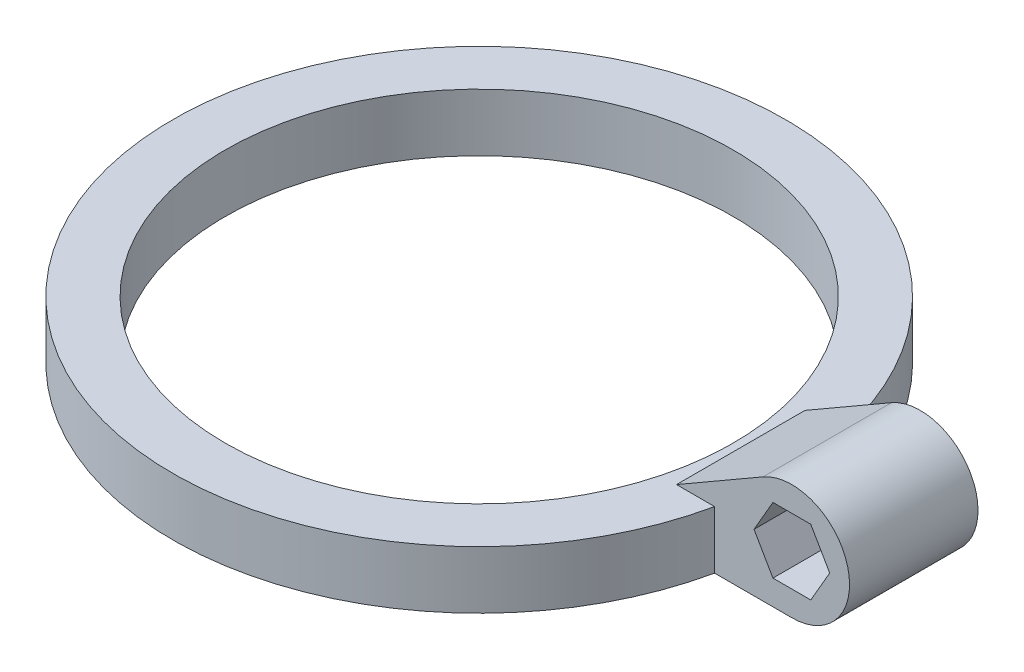
from build123d import *

# Parameters (mm, degrees)
SKETCH2_R                      = 38.75
BOSS_EXTRUDE1_DEPTH            = 8.8
BOSS_EXTRUDE2_DEPTH            = 9.8
BOSS_EXTRUDE2_DEPTH_BACK       = 9.8
CUT_EXTRUDE1_REACH             = 116.591
CUT_EXTRUDE1_DIRECTION_2_REACH = 116.591
CUT_EXTRUDE2_REACH             = 116.591
SKETCH5_W                      = 2
SKETCH5_H                      = 1


with BuildPart() as part:
    # Sketch2 → Boss-Extrude1 (new body)
    with BuildSketch(Plane(origin=(0, 0, 0), x_dir=(1, 0, 0), z_dir=(0, 1, 0))):
        with BuildLine():
            Line((-11.788704897, -9.8), (0, -9.8))
            Line((0, -9.8), (0, 9.8))
            Line((0, 9.8), (-11.788704897, 9.8))
            ThreePointArc((-11.788704897, 9.8), (-104.25, 0), (-11.788704897, -9.8))
        make_face()
        with Locations((-57.5, 0)):
            Circle(SKETCH2_R, mode=Mode.SUBTRACT)
    extrude(amount=-BOSS_EXTRUDE1_DEPTH)

    # Sketch3 → Boss-Extrude2 (add, two sides: drawn at the far end of the back side and taken through both)
    with BuildSketch(Plane.XY.offset(-BOSS_EXTRUDE2_DEPTH_BACK)):
        with BuildLine():
            Line((0, -8.8), (0, 0))
            Line((0, 0), (-17.6, 0))
            Line((-17.6, 0), (-4.4, 7.621023553))
            ThreePointArc((-4.4, 7.621023553), (8.500147271, 2.277607597), (0, -8.8))
        make_face()
    extrude(amount=BOSS_EXTRUDE2_DEPTH + BOSS_EXTRUDE2_DEPTH_BACK)

    # Sketch4 → Cut-Extrude1 (cut, up to next)
    with BuildSketch(Plane.XY, mode=Mode.PRIVATE) as cut_extrude1_sk1:
        Polygon((5.773502692, 0), (2.886751346, 5), (-2.886751346, 5), (-5.773502692, 0), (-2.886751346, -5), (2.886751346, -5), align=None)
    cut_extrude1_tool1 = extrude(cut_extrude1_sk1.sketch, amount=-CUT_EXTRUDE1_REACH, mode=Mode.PRIVATE) & part.part
    add(cut_extrude1_tool1.solids().sort_by_distance((0, 0, 0))[0], mode=Mode.SUBTRACT)

    # Sketch4 → Cut-Extrude1 direction 2 (cut, up to next)
    with BuildSketch(Plane.XY, mode=Mode.PRIVATE) as cut_extrude1_direction_2_sk1:
        Polygon((5.773502692, 0), (2.886751346, 5), (-2.886751346, 5), (-5.773502692, 0), (-2.886751346, -5), (2.886751346, -5), align=None)
    cut_extrude1_direction_2_tool1 = extrude(cut_extrude1_direction_2_sk1.sketch, amount=CUT_EXTRUDE1_DIRECTION_2_REACH, mode=Mode.PRIVATE) & part.part
    add(cut_extrude1_direction_2_tool1.solids().sort_by_distance((0, 0, 0))[0], mode=Mode.SUBTRACT)

    # Sketch5 → Cut-Extrude2 (cut, up to next)
    with BuildSketch(Plane.XY, mode=Mode.PRIVATE) as cut_extrude2_sk1:
        with Locations((0, -5.5)):
            Rectangle(SKETCH5_W, SKETCH5_H)
    cut_extrude2_tool1 = extrude(cut_extrude2_sk1.sketch, amount=-CUT_EXTRUDE2_REACH, mode=Mode.PRIVATE) & part.part
    add(cut_extrude2_tool1.solids().sort_by_distance((0, -5.5, 0))[0], mode=Mode.SUBTRACT)


solid = part.part
